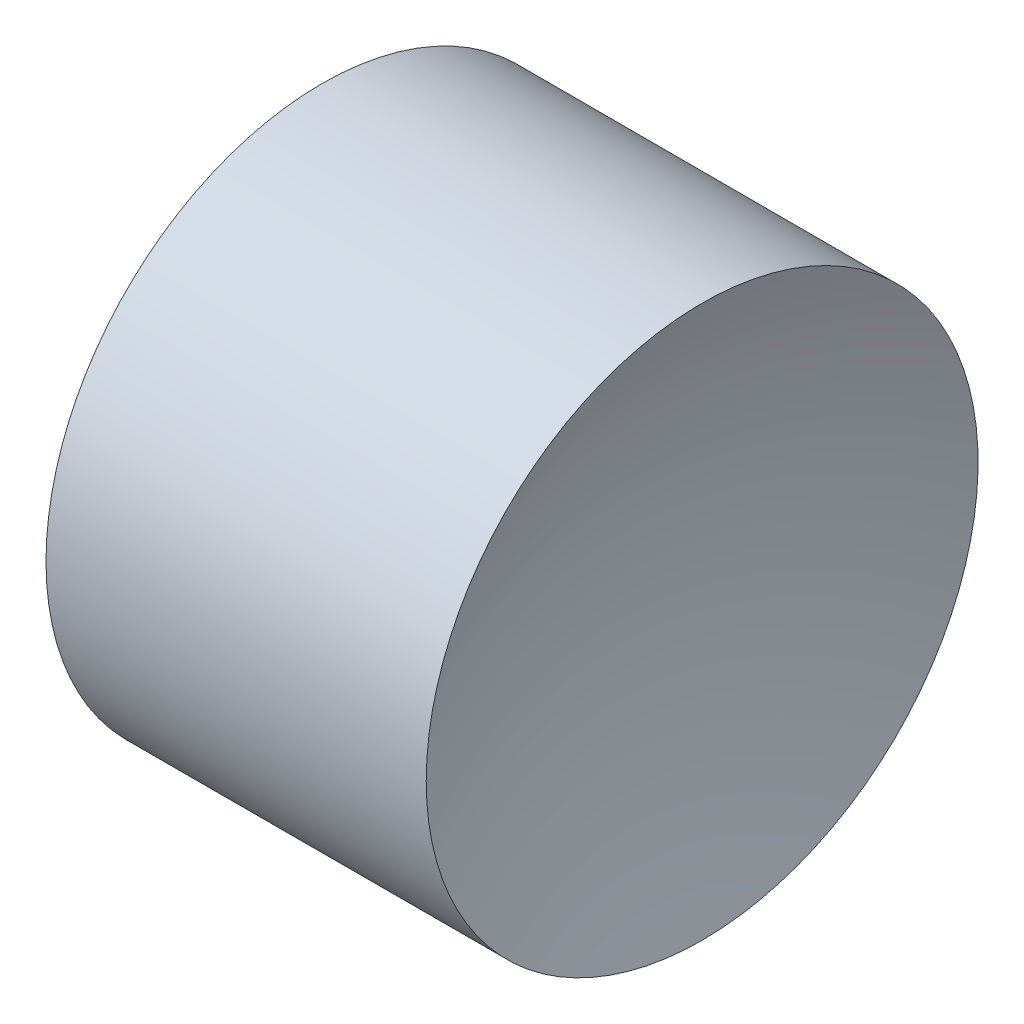
from build123d import *


with BuildPart() as part:
    # 草图1 → 旋转1 (revolve)
    with BuildSketch(Plane.XY, mode=Mode.PRIVATE) as revolve_1_sk:
        with BuildLine():
            Line((5.489613269, 3.261130144), (6.489613269, 3.261130144))
            ThreePointArc((6.489613269, 3.261130144), (6.537277901, 3.769982056), (6.678613465, 4.261130144))
            Line((6.678613465, 4.261130144), (5.989613269, 4.261130144))
            Line((5.989613269, 4.261130144), (5.300613073, 4.261130144))
            ThreePointArc((5.300613073, 4.261130144), (5.441948636, 3.769982056), (5.489613269, 3.261130144))
        make_face()
    revolve(revolve_1_sk.sketch.rotate(Axis((5.306232639, 3.261130144, 0), (1, 0, 0)), 90), axis=Axis((5.306232639, 3.261130144, 0), (1, 0, 0)))  # turned: the seam where the file's is


solid = part.part
